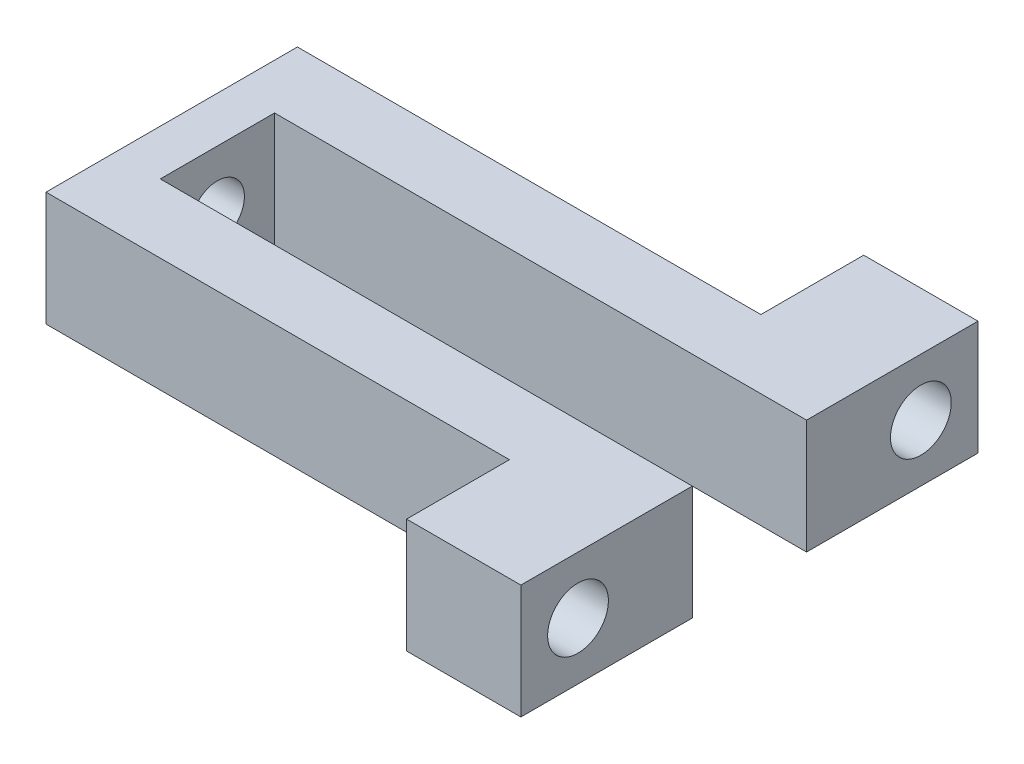
from build123d import *

# Parameters (mm, degrees)
SKETCH1_W                                     = 64.2
SKETCH1_H                                     = 50.8
BOSS_EXTRUDE1_DEPTH                           = 12.7
SKETCH4_W                                     = 51.5
SKETCH4_H                                     = 11.43
SKETCH4_W_2                                   = 59.12
SKETCH4_H_2                                   = 12.7
CUT_EXTRUDE1_DEPTH                            = 12.7
CBORE_FOR_1_4_SOCKET_HEAD_CAP_SCREW1_AT_COUNT = 2
CBORE_FOR_1_4_SOCKET_HEAD_CAP_SCREW1_AT_PITCH = 38.1
F_6_0MM_DOWEL_HOLE1_D                         = 6


with BuildPart() as part:
    # Sketch1 → Boss-Extrude1 (new body)
    with BuildSketch(Plane(origin=(0, 0, 0), x_dir=(1, 0, 0), z_dir=(0, 1, 0))):
        Rectangle(SKETCH1_W, SKETCH1_H)
    extrude(amount=BOSS_EXTRUDE1_DEPTH)

    # Sketch4 → Cut-Extrude1 (cut)
    with BuildSketch(Plane(origin=(0, 12.7, 0), x_dir=(1, 0, 0), z_dir=(0, 1, 0))):
        with Locations((-6.35, -19.685)):
            Rectangle(SKETCH4_W, SKETCH4_H)
        with Locations((-6.35, 19.685)):
            Rectangle(SKETCH4_W, SKETCH4_H)
        with Locations((2.54, 0)):
            Rectangle(SKETCH4_W_2, SKETCH4_H_2)
    extrude(amount=-CUT_EXTRUDE1_DEPTH, mode=Mode.SUBTRACT)

    # Sketch6 → CBORE for 1/4 Socket Head Cap Screw1 (revolve, cut)
    with BuildSketch(Plane(origin=(19.4, 6.35, 19.05), x_dir=(0, 0, 1), z_dir=(0, 1, 0))):
        Polygon((0, 0), (0, 12.7), (3.3782, 12.7), (3.3782, 6.35), (5.55625, 6.35), (5.55625, 0), align=None)
    cbore_for_1_4_socket_head_cap_screw1 = revolve(axis=Axis((13.05, 6.35, 19.05), (1, 0, 0)), mode=Mode.SUBTRACT)

    # CBORE for 1/4 Socket Head Cap Screw1 at: CBORE for 1/4 Socket Head Cap Screw1 ×2
    with Locations(*[(0, 0, -i * CBORE_FOR_1_4_SOCKET_HEAD_CAP_SCREW1_AT_PITCH) for i in range(1, CBORE_FOR_1_4_SOCKET_HEAD_CAP_SCREW1_AT_COUNT)]):
        add(cbore_for_1_4_socket_head_cap_screw1, mode=Mode.SUBTRACT)

    # Ø6.0mm Dowel Hole1 (through all)
    with Locations(Plane.ZY.offset(32.1)):
        with Locations((0, 6.35)):
            Hole(F_6_0MM_DOWEL_HOLE1_D / 2)


solid = part.part
